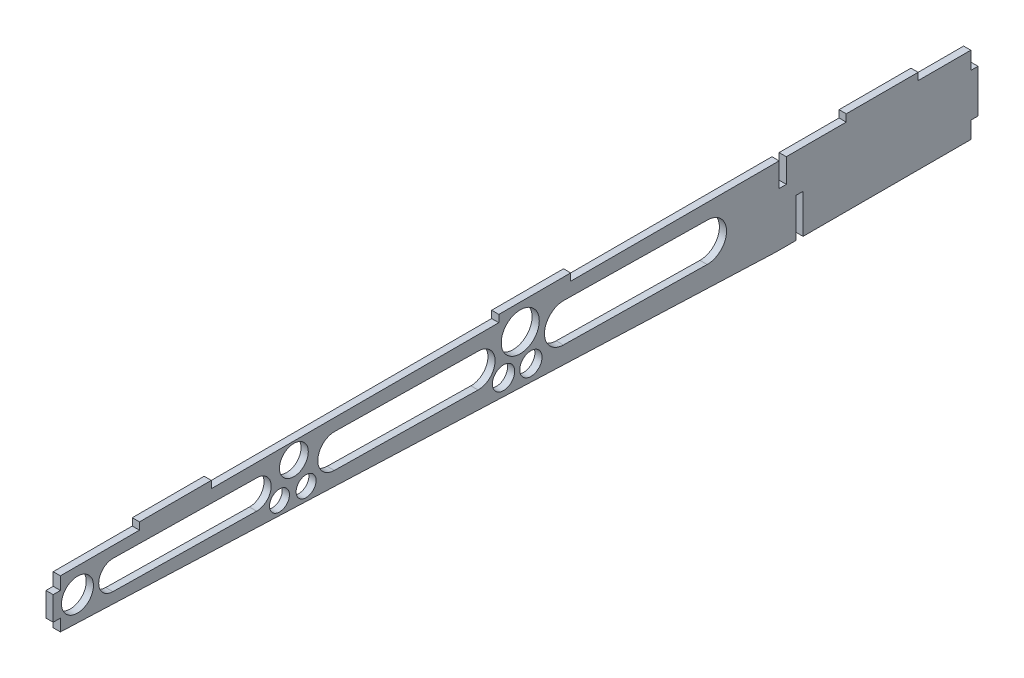
from build123d import *

# Parameters (mm, degrees)
BOSS_EXTRUDE1_DEPTH = 3
SKETCH2_W           = 3
SKETCH2_H           = 10
SKETCH2_W_2         = 30
SKETCH2_H_2         = 3
BOSS_EXTRUDE2_DEPTH = 3
CUT_EXTRUDE1_DEPTH  = 10
SKETCH4_W           = 3
SKETCH4_H           = 10
SKETCH4_H_2         = 16.31
CUT_EXTRUDE2_DEPTH  = 10
SKETCH5_W           = 3
SKETCH5_H           = 13.703534411
SKETCH5_H_2         = 13.791377581
CUT_EXTRUDE3_DEPTH  = 10
SKETCH6_R           = 6.665876203
SKETCH6_R_2         = 6.014739453
SKETCH6_R_3         = 4.167493344
SKETCH6_R_4         = 7.942691131
SKETCH6_R_5         = 4.658905865
CUT_EXTRUDE4_DEPTH  = 10


with BuildPart() as part:
    # Sketch1 → Boss-Extrude1 (new body)
    with BuildSketch(Plane(origin=(0, 0, 0), x_dir=(0, 0, -1), z_dir=(1, 0, 0))):
        Polygon((-383, 12.016330065), (-84.3, 0), (0, 0), (0, 32.31), (-383, 32.31), align=None)
    extrude(amount=BOSS_EXTRUDE1_DEPTH)

    # Sketch2 → Boss-Extrude2 (add)
    with BuildSketch(Plane(origin=(3, 0, 0), x_dir=(0, 0, -1), z_dir=(1, 0, 0))):
        with Locations((-384.5, 22.016330065)):
            Rectangle(SKETCH2_W, SKETCH2_H)
        with Locations((-335, 33.81)):
            Rectangle(SKETCH2_W_2, SKETCH2_H_2)
        with Locations((-40, 33.81)):
            Rectangle(SKETCH2_W_2, SKETCH2_H_2)
        with Locations((-185, 33.81)):
            Rectangle(SKETCH2_W_2, SKETCH2_H_2)
    extrude(amount=-BOSS_EXTRUDE2_DEPTH)

    # Sketch3 → Cut-Extrude1 (cut)
    with BuildSketch(Plane(origin=(3, 0, 0), x_dir=(0, 0, -1), z_dir=(1, 0, 0))):
        with BuildLine():
            Line((-360.908901745, 27.636018628), (-300.908901745, 26.724931053))
            ThreePointArc((-300.908901745, 26.724931053), (-295.000691614, 20.634524412), (-301.091098255, 14.726314282))
            Line((-301.091098255, 14.726314282), (-361.091098255, 15.637401857))
            ThreePointArc((-361.091098255, 15.637401857), (-366.999308386, 21.727808498), (-360.908901745, 27.636018628))
        make_face()
        with BuildLine():
            Line((-268.447308122, 27.232123759), (-208.447308122, 26.321036184))
            ThreePointArc((-208.447308122, 26.321036184), (-201.554396303, 19.215561769), (-208.659870718, 12.32264995))
            Line((-208.659870718, 12.32264995), (-268.659870718, 13.233737525))
            ThreePointArc((-268.659870718, 13.233737525), (-275.552782537, 20.33921194), (-268.447308122, 27.232123759))
        make_face()
        with BuildLine():
            Line((-172.817042181, 26.780113256), (-112.817042181, 25.869025681))
            ThreePointArc((-112.817042181, 25.869025681), (-104.939428674, 17.748483493), (-113.059970863, 9.870869986))
            Line((-113.059970863, 9.870869986), (-173.059970863, 10.781957561))
            ThreePointArc((-173.059970863, 10.781957561), (-180.93758437, 18.902499749), (-172.817042181, 26.780113256))
        make_face()
    extrude(amount=-CUT_EXTRUDE1_DEPTH, mode=Mode.SUBTRACT)

    # Sketch4 → Cut-Extrude2 (cut)
    with BuildSketch(Plane(origin=(3, 0, 0), x_dir=(0, 0, -1), z_dir=(1, 0, 0))):
        with Locations((-81.5, 27.31)):
            Rectangle(SKETCH4_W, SKETCH4_H)
        with Locations((-74.5, 8.155)):
            Rectangle(SKETCH4_W, SKETCH4_H_2)
    extrude(amount=-CUT_EXTRUDE2_DEPTH, mode=Mode.SUBTRACT)

    # Sketch5 → Cut-Extrude3 (cut)
    with BuildSketch(Plane(origin=(3, 0, 0), x_dir=(0, 0, -1), z_dir=(1, 0, 0))):
        with Locations((-1.5, 31.851767205)):
            Rectangle(SKETCH5_W, SKETCH5_H)
        with Locations((-1.5, 0.104311209)):
            Rectangle(SKETCH5_W, SKETCH5_H_2)
    extrude(amount=-CUT_EXTRUDE3_DEPTH, mode=Mode.SUBTRACT)

    # Sketch6 → Cut-Extrude4 (cut)
    with BuildSketch(Plane(origin=(3, 0, 0), x_dir=(0, 0, -1), z_dir=(1, 0, 0))):
        with Locations((-375.865428414, 21.928511603)):
            Circle(SKETCH6_R)
        with Locations((-285.544135062, 25.435251305)):
            Circle(SKETCH6_R_2)
        with Locations((-280.443646207, 13.449102496)):
            Circle(SKETCH6_R_3)
        with Locations((-291.558874515, 13.83163916)):
            Circle(SKETCH6_R_3)
        with Locations((-191.057579024, 24.542665756)):
            Circle(SKETCH6_R_4)
        with Locations((-186.614565866, 10.842366657)):
            Circle(SKETCH6_R_5)
        with Locations((-198.037933391, 11.447109955)):
            Circle(SKETCH6_R_5)
    extrude(amount=-CUT_EXTRUDE4_DEPTH, mode=Mode.SUBTRACT)


solid = part.part
